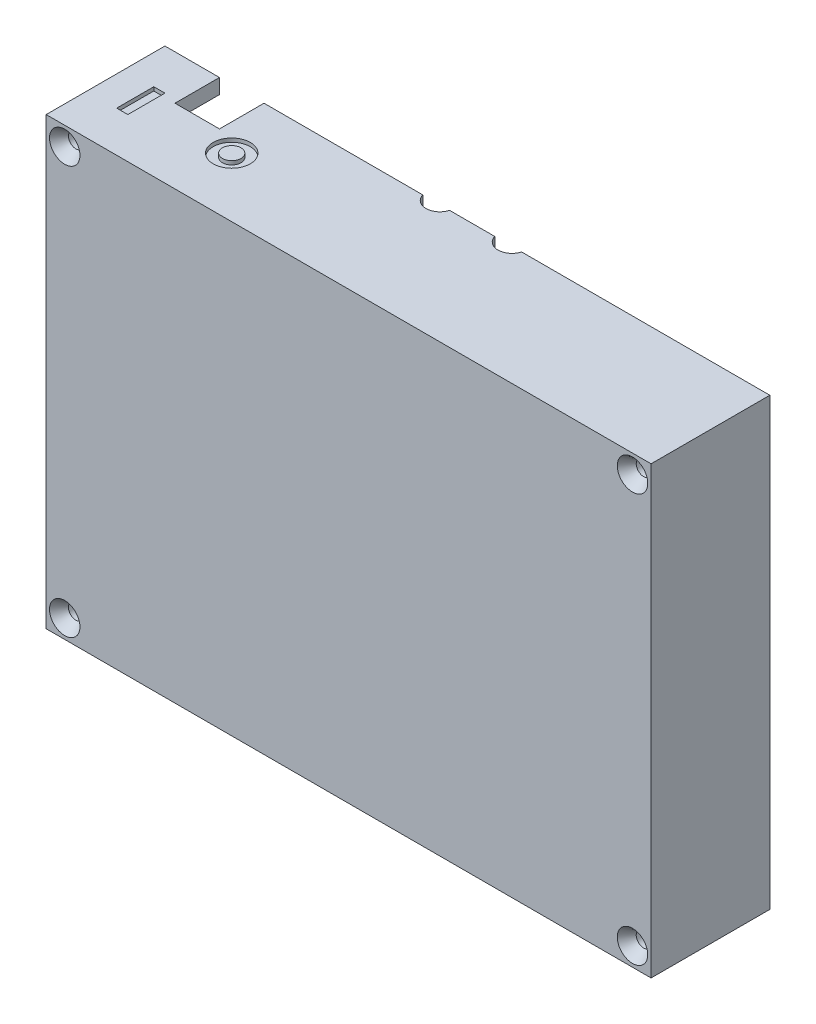
from build123d import *

# Parameters (mm, degrees)
SKETCH1_W             = 81.5
SKETCH1_H             = 60
BOSS_EXTRUDE1_DEPTH   = 14
SKETCH3_W             = 81.5
SKETCH3_H             = 60
BOSS_EXTRUDE2_DEPTH   = 2
SKETCH4_R             = 3.25
CUT_EXTRUDE1_DEPTH    = 2
SKETCH5_R             = 1.875
CUT_EXTRUDE2_DEPTH    = 2
SKETCH6_R             = 0.9
BOSS_EXTRUDE3_DEPTH   = 9
BOSS_EXTRUDE4_DEPTH   = 9
FILLET1_R             = 3
SKETCH9_R             = 1
CUT_EXTRUDE3_DEPTH    = 17
CHAMFER1_SIZE         = 1.5
CHAMFER1_SIZE2        = 1.050311307
CHAMFER1_PART_2_SIZE  = 1.5
CHAMFER1_PART_2_SIZE2 = 1.050311307
CHAMFER1_PART_3_SIZE  = 1.5
CHAMFER1_PART_3_SIZE2 = 1.050311307
CHAMFER1_PART_4_SIZE  = 1.5
CHAMFER1_PART_4_SIZE2 = 1.050311307
CUT_EXTRUDE4_REACH    = 62
SKETCH10_W            = 6
SKETCH10_H            = 6
CHAMFER2_SIZE         = 1
SKETCH11_R            = 2.5
SKETCH11_R_2          = 1.25
SKETCH11_W            = 1.5
SKETCH11_H            = 5
CUT_EXTRUDE5_DEPTH    = 0.5


with BuildPart() as part:
    # Sketch1 → Boss-Extrude1 (new body)
    with BuildSketch(Plane.XY):
        with Locations((2.5, -1)):
            Rectangle(SKETCH1_W, SKETCH1_H)
        with BuildLine():
            Line((-36.25, -27), (-36.25, 24.25))
            ThreePointArc((-36.25, 24.25), (-34.218257349, 24.968257349), (-33.5, 27))
            Line((-33.5, 27), (38.5, 27))
            ThreePointArc((38.5, 27), (39.218257349, 24.968257349), (41.25, 24.25))
            Line((41.25, 24.25), (41.25, -27))
            Line((41.25, -27), (-36.25, -27))
        make_face(mode=Mode.SUBTRACT)
    extrude(amount=BOSS_EXTRUDE1_DEPTH)

    # Sketch3 → Boss-Extrude2 (add)
    with BuildSketch(Plane.XY.offset(14)):
        with Locations((2.5, -1)):
            Rectangle(SKETCH3_W, SKETCH3_H)
    extrude(amount=BOSS_EXTRUDE2_DEPTH)

    # Sketch4 → Cut-Extrude1 (cut)
    with BuildSketch(Plane.ZY.offset(38.25)):
        with Locations((0.5, -18)):
            Circle(SKETCH4_R)
        with Locations((0.5, -2)):
            Circle(SKETCH4_R)
        with Locations((0.5, 14)):
            Circle(SKETCH4_R)
    extrude(amount=-CUT_EXTRUDE1_DEPTH, mode=Mode.SUBTRACT)

    # Sketch5 → Cut-Extrude2 (cut)
    with BuildSketch(Plane(origin=(0, 29, 0), x_dir=(1, 0, 0), z_dir=(0, 1, 0))):
        with Locations((8, 0.5)):
            Circle(SKETCH5_R)
        with Locations((-1.7, 0.5)):
            Circle(SKETCH5_R)
    extrude(amount=-CUT_EXTRUDE2_DEPTH, mode=Mode.SUBTRACT)

    # Sketch6 → Boss-Extrude3 (add)
    with BuildSketch(Plane(origin=(0, 0, 14), x_dir=(-1, 0, 0), z_dir=(0, 0, -1))):
        with BuildLine():
            Line((-31, -24.25), (-31, -27))
            Line((-31, -27), (-41.25, -27))
            Line((-41.25, -27), (-41.25, -21.75))
            Line((-41.25, -21.75), (-33.5, -21.75))
            ThreePointArc((-33.5, -21.75), (-31.732233047, -22.482233047), (-31, -24.25))
        make_face()
        with Locations((-33.5, -24.25)):
            Circle(SKETCH6_R, mode=Mode.SUBTRACT)
        with BuildLine():
            Line((-41.25, 19.25), (-33.5, 19.25))
            ThreePointArc((-33.5, 19.25), (-31.732233047, 19.982233047), (-31, 21.75))
            Line((-31, 21.75), (-31, 27))
            Line((-31, 27), (-41.25, 27))
            Line((-41.25, 27), (-41.25, 19.25))
        make_face()
        with Locations((-33.5, 21.75)):
            Circle(SKETCH6_R, mode=Mode.SUBTRACT)
    extrude(amount=BOSS_EXTRUDE3_DEPTH)

    # Sketch7 → Boss-Extrude4 (add)
    with BuildSketch(Plane(origin=(0, 0, 14), x_dir=(-1, 0, 0), z_dir=(0, 0, -1))):
        Polygon((36.25, -27), (34.25, -27), (34.25, 24), (33.25, 24), (33.25, 27), (36.25, 27), align=None)
    extrude(amount=BOSS_EXTRUDE4_DEPTH)

    # Fillet1
    fillet1_edges = [part.edges().sort_by_distance(p)[0] for p in [
        (41.25, -27, 2.5),
        (-36.25, -27, 2.5),
    ]]
    fillet(fillet1_edges, radius=FILLET1_R)

    # Sketch9 → Cut-Extrude3 (cut, through all)
    with BuildSketch(Plane(origin=(0, 0, 0), x_dir=(-1, 0, 0), z_dir=(0, 0, -1))):
        with Locations((35.75, -28.5)):
            Circle(SKETCH9_R)
        with Locations((-40.75, -28.5)):
            Circle(SKETCH9_R)
        with Locations((-40.75, 26.5)):
            Circle(SKETCH9_R)
        with Locations((35.75, 26.5)):
            Circle(SKETCH9_R)
    extrude(amount=-CUT_EXTRUDE3_DEPTH, mode=Mode.SUBTRACT)

    # Chamfer1
    chamfer1_edges = [part.edges().sort_by_distance(p)[0] for p in [
        (-34.75, 26.5, 16),
    ]]
    chamfer1_side = [part.faces().sort_by_distance(p)[0] for p in [
        (-34.75, 26.5, 8),
    ]]
    chamfer(chamfer1_edges, length=CHAMFER1_SIZE, length2=CHAMFER1_SIZE2, reference=chamfer1_side[0])

    # Chamfer1 part 2
    chamfer1_part_2_edges = [part.edges().sort_by_distance(p)[0] for p in [
        (41.75, 26.5, 16),
    ]]
    chamfer1_part_2_side = [part.faces().sort_by_distance(p)[0] for p in [
        (41.75, 26.5, 8),
    ]]
    chamfer(chamfer1_part_2_edges, length=CHAMFER1_PART_2_SIZE, length2=CHAMFER1_PART_2_SIZE2, reference=chamfer1_part_2_side[0])

    # Chamfer1 part 3
    chamfer1_part_3_edges = [part.edges().sort_by_distance(p)[0] for p in [
        (41.75, -28.5, 16),
    ]]
    chamfer1_part_3_side = [part.faces().sort_by_distance(p)[0] for p in [
        (41.75, -28.5, 8),
    ]]
    chamfer(chamfer1_part_3_edges, length=CHAMFER1_PART_3_SIZE, length2=CHAMFER1_PART_3_SIZE2, reference=chamfer1_part_3_side[0])

    # Chamfer1 part 4
    chamfer1_part_4_edges = [part.edges().sort_by_distance(p)[0] for p in [
        (-34.75, -28.5, 16),
    ]]
    chamfer1_part_4_side = [part.faces().sort_by_distance(p)[0] for p in [
        (-34.75, -28.5, 8),
    ]]
    chamfer(chamfer1_part_4_edges, length=CHAMFER1_PART_4_SIZE, length2=CHAMFER1_PART_4_SIZE2, reference=chamfer1_part_4_side[0])

    # Sketch10 → Cut-Extrude4 (cut, up to next)
    with BuildSketch(Plane(origin=(0, 29, 0), x_dir=(1, 0, 0), z_dir=(0, 1, 0)), mode=Mode.PRIVATE) as cut_extrude4_sk1:
        with Locations((-27.9, -3)):
            Rectangle(SKETCH10_W, SKETCH10_H)
    cut_extrude4_tool1 = extrude(cut_extrude4_sk1.sketch, amount=-CUT_EXTRUDE4_REACH, mode=Mode.PRIVATE) & part.part
    add(cut_extrude4_tool1.solids().sort_by_distance((-27.9, 29, 3))[0], mode=Mode.SUBTRACT)

    # Chamfer2
    chamfer2_edges = [part.edges().sort_by_distance(p)[0] for p in [
        (-38.25, -18, 3.75),
        (-38.25, -2, 3.75),
        (-38.25, 14, 3.75),
    ]]
    chamfer(chamfer2_edges, length=CHAMFER2_SIZE)

    # Sketch11 → Cut-Extrude5 (cut)
    with BuildSketch(Plane(origin=(0, 29, 0), x_dir=(1, 0, 0), z_dir=(0, 1, 0))):
        with Locations((-21.25, -8)):
            Circle(SKETCH11_R)
        with Locations((-21.25, -8)):
            Circle(SKETCH11_R_2, mode=Mode.SUBTRACT)
        with Locations((-33.5, -8)):
            Rectangle(SKETCH11_W, SKETCH11_H)
    extrude(amount=-CUT_EXTRUDE5_DEPTH, mode=Mode.SUBTRACT)


solid = part.part
